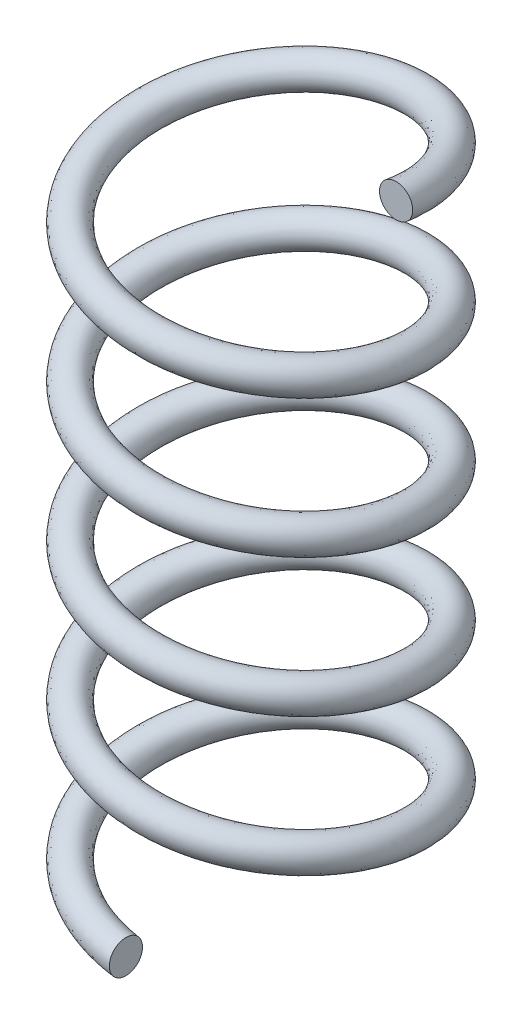
from build123d import *

# Parameters (mm, degrees)
SWEEP1_PITCH  = 25
SWEEP1_HEIGHT = 118.75
SWEEP1_RADIUS = 24.5
SKETCH7_R     = 3.01


with BuildPart() as part:
    # Sweep1: sweep along a helix
    with BuildLine() as sweep1_path:
        Helix(SWEEP1_PITCH, SWEEP1_HEIGHT, SWEEP1_RADIUS, center=(0, 0, 0), direction=(0, 1, 0), lefthand=True)
    # Sketch7 → Sweep1 (sweep)
    with BuildSketch(Plane(origin=(0, 0, 0), x_dir=(0, 0, -1), z_dir=(1, 0, 0))):
        with Locations((-24.5, 0)):
            Circle(SKETCH7_R)
    sweep(path=sweep1_path.line, is_frenet=True)


solid = part.part
